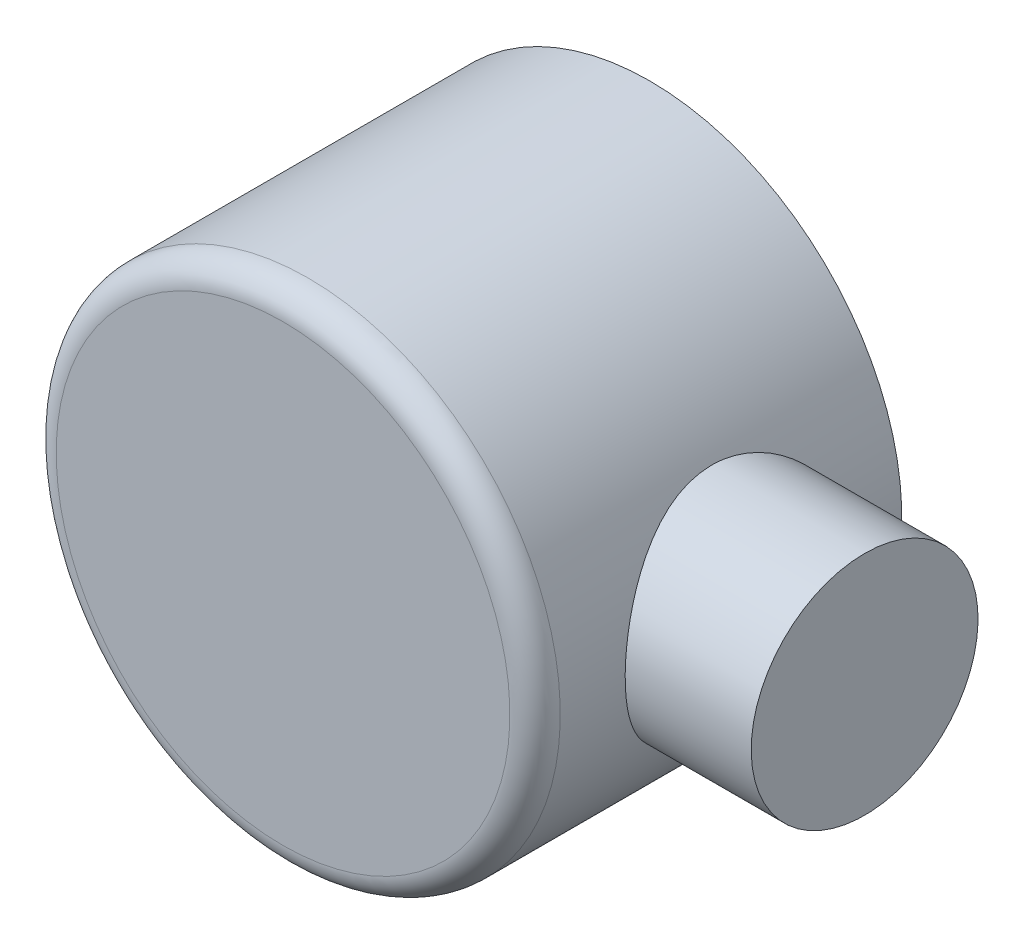
from build123d import *

# Parameters (mm, degrees)
SKETCH2_R             = 50
BOSS_EXTRUDE1_DEPTH   = 64.75
BOSS_EXTRUDE2_START   = 8
SKETCH4_R             = 50
BOSS_EXTRUDE2_DEPTH   = 8
FILLET1_R             = 5
BODY_MOVE_COPY2_ANGLE = 120
SKETCH5_R             = 42.5
CUT_EXTRUDE1_DEPTH    = 60


with BuildPart() as part:
    # Sketch2 → Boss-Extrude1 (new body)
    with BuildSketch(Plane(origin=(0, 0, 0), x_dir=(0, 0, -1), z_dir=(1, 0, 0))):
        Circle(SKETCH2_R)
    extrude(amount=BOSS_EXTRUDE1_DEPTH)

    # Sketch3 → Revolve1 (revolve)
    with BuildSketch(Plane.ZY.offset(-32.375)):
        with BuildLine():
            Line((0, 75), (0, 50))
            ThreePointArc((0, 50), (11.563490229, 48.644482665), (22.5, 44.651427749))
            Line((22.5, 44.651427749), (22.5, 75))
            Line((22.5, 75), (0, 75))
        make_face()
    revolve(axis=Axis((32.375, 50, 0), (0, 1, 0)))

    # Sketch4 → Boss-Extrude2 (add)
    with BuildSketch(Plane.ZY.offset(BOSS_EXTRUDE2_START)):
        Circle(SKETCH4_R)
    extrude(amount=-BOSS_EXTRUDE2_DEPTH)

    # Fillet1
    fillet1_edges = [part.edges().sort_by_distance(p)[0] for p in [
        (-8, 0, -50),
    ]]
    fillet(fillet1_edges, radius=FILLET1_R)


with BuildPart() as part_1:
    # Body-Move_Copy1: moved
    add(part.part.moved(Location((-32.38, 0, 0))))


with BuildPart() as part_2:
    # Body-Move_Copy2: moved
    add(part_1.part.rotate(Axis((0, 0, 0), (0.5773502691896272, 0.5773502691896252, -0.5773502691896252)), BODY_MOVE_COPY2_ANGLE))

    # Sketch5 → Cut-Extrude1 (cut)
    with BuildSketch(Plane(origin=(0, 0, -32.37), x_dir=(-1, 0, 0), z_dir=(0, 0, -1))):
        Circle(SKETCH5_R)
    extrude(amount=-CUT_EXTRUDE1_DEPTH, mode=Mode.SUBTRACT)


solid = part_2.part
